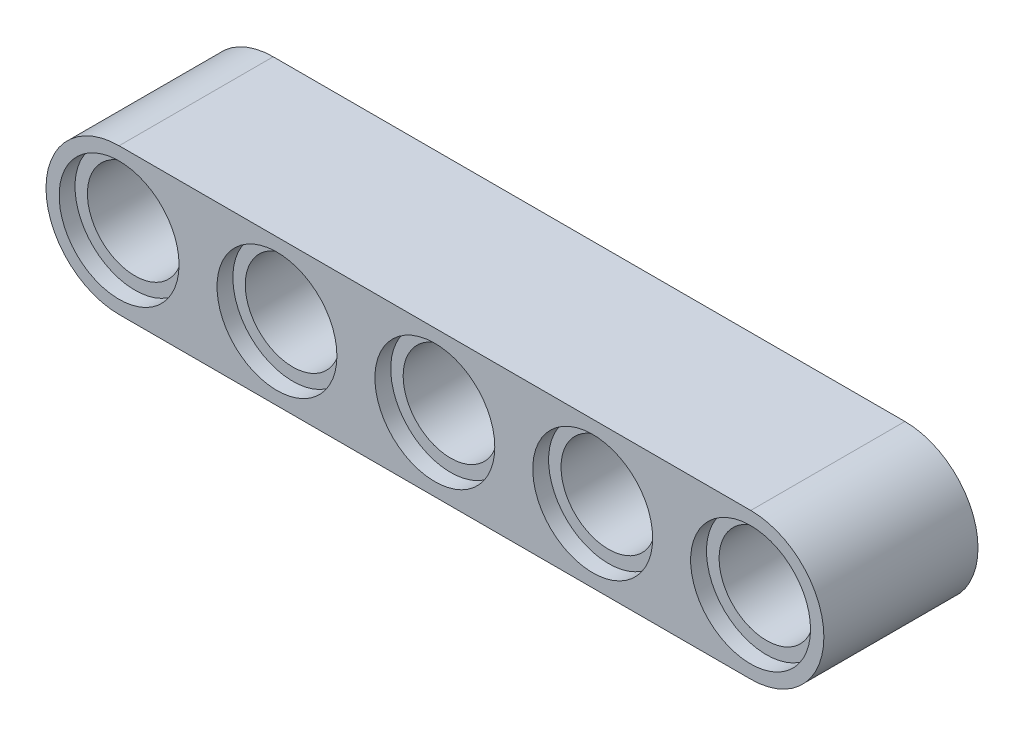
from build123d import *

# Parameters (mm, degrees)
SKETCH1_R                = 24
BOSS_EXTRUDE4_DEPTH      = 77.8
BOSS_EXTRUDE4_DEPTH_BACK = 0.01
SKETCH6_R                = 30.26307147
CUT_EXTRUDE1_DEPTH       = 8
SKETCH9_R                = 30.265
CUT_EXTRUDE2_DEPTH       = 8


with BuildPart() as part:
    # Sketch1 → Boss-Extrude4 (new body, two sides)
    with BuildSketch(Plane.XY) as boss_extrude4_sk:
        with BuildLine():
            Line((-240.6, 12.003445454), (78.3, 12.003445454))
            ThreePointArc((78.3, 12.003445454), (115.2, -24.896554546), (78.3, -61.796554546))
            Line((78.3, -61.796554546), (-240.6, -61.796554546))
            ThreePointArc((-240.6, -61.796554546), (-277.5, -24.896554546), (-240.6, 12.003445454))
        make_face()
        with Locations((-240.6, -24.896554546)):
            Circle(SKETCH1_R, mode=Mode.SUBTRACT)
        with Locations((-160.9, -24.896554546)):
            Circle(SKETCH1_R, mode=Mode.SUBTRACT)
        with Locations((-81.2, -24.896554546)):
            Circle(SKETCH1_R, mode=Mode.SUBTRACT)
        with Locations((-1.5, -24.896554546)):
            Circle(SKETCH1_R, mode=Mode.SUBTRACT)
        with Locations((78.3, -24.896554546)):
            Circle(SKETCH1_R, mode=Mode.SUBTRACT)
    extrude(amount=BOSS_EXTRUDE4_DEPTH)
    extrude(boss_extrude4_sk.sketch, amount=-BOSS_EXTRUDE4_DEPTH_BACK)

    # Sketch6 → Cut-Extrude1 (cut)
    with BuildSketch(Plane.XY.offset(77.8)):
        with Locations((-240.6, -24.896554546)):
            Circle(SKETCH6_R)
        with Locations((-160.9, -24.896554546)):
            Circle(SKETCH6_R)
        with Locations((-81.2, -24.896554546)):
            Circle(SKETCH6_R)
        with Locations((-1.5, -24.896554546)):
            Circle(SKETCH6_R)
        with Locations((78.2, -24.896554546)):
            Circle(SKETCH6_R)
    extrude(amount=-CUT_EXTRUDE1_DEPTH, mode=Mode.SUBTRACT)

    # Sketch9 → Cut-Extrude2 (cut)
    with BuildSketch(Plane(origin=(0, 0, -0.01), x_dir=(-1, 0, 0), z_dir=(0, 0, -1))):
        with Locations((-78.3, -24.896554546)):
            Circle(SKETCH9_R)
        with Locations((1.4, -24.896554546)):
            Circle(SKETCH9_R)
        with Locations((81.1, -24.896554546)):
            Circle(SKETCH9_R)
        with Locations((160.8, -24.896554546)):
            Circle(SKETCH9_R)
        with Locations((240.5, -24.896554546)):
            Circle(SKETCH9_R)
    extrude(amount=-CUT_EXTRUDE2_DEPTH, mode=Mode.SUBTRACT)


solid = part.part
